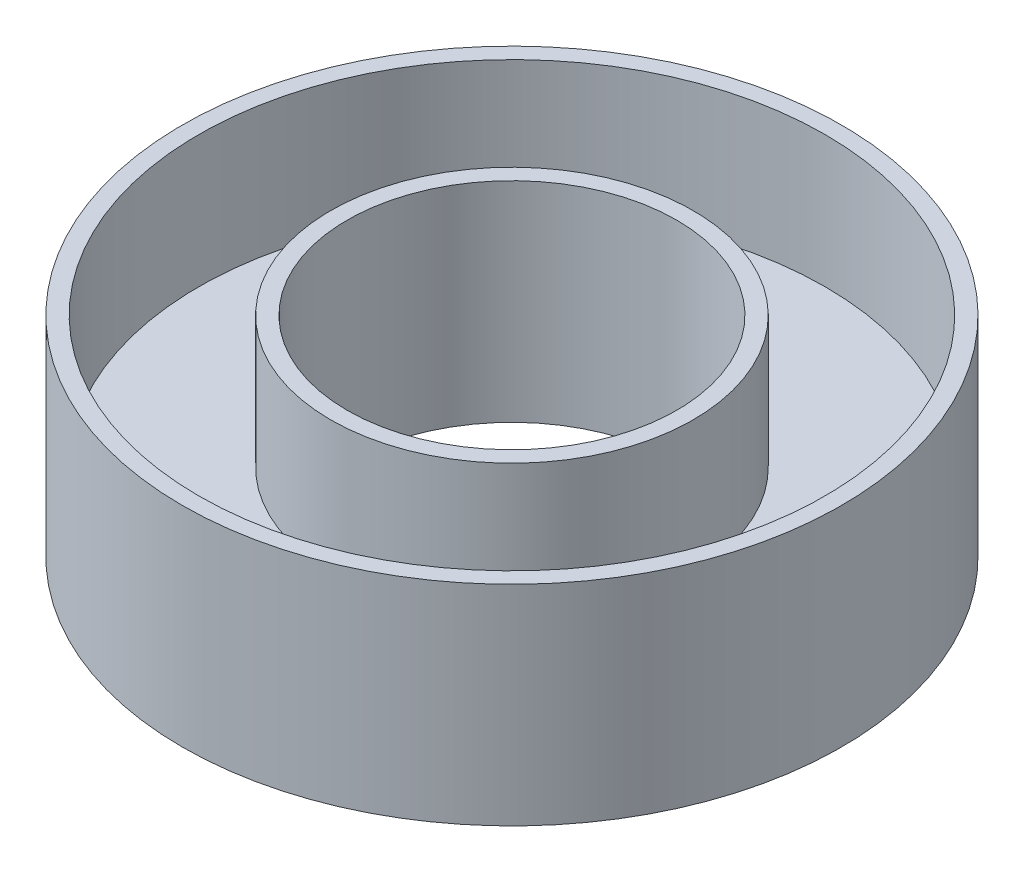
from build123d import *

# Parameters (mm, degrees)
SKETCH1_R           = 5
SKETCH1_R_2         = 2.5
BOSS_EXTRUDE1_DEPTH = 3.175
SKETCH2_R           = 4.75
SKETCH2_R_2         = 2.75
CUT_EXTRUDE1_DEPTH  = 2


with BuildPart() as part:
    # Sketch1 → Boss-Extrude1 (new body)
    with BuildSketch(Plane(origin=(0, 0, 0), x_dir=(1, 0, 0), z_dir=(0, 1, 0))):
        Circle(SKETCH1_R)
        Circle(SKETCH1_R_2, mode=Mode.SUBTRACT)
    extrude(amount=BOSS_EXTRUDE1_DEPTH)

    # Sketch2 → Cut-Extrude1 (cut)
    with BuildSketch(Plane(origin=(0, 3.175, 0), x_dir=(1, 0, 0), z_dir=(0, 1, 0))):
        Circle(SKETCH2_R)
        Circle(SKETCH2_R_2, mode=Mode.SUBTRACT)
    extrude(amount=-CUT_EXTRUDE1_DEPTH, mode=Mode.SUBTRACT)


solid = part.part
